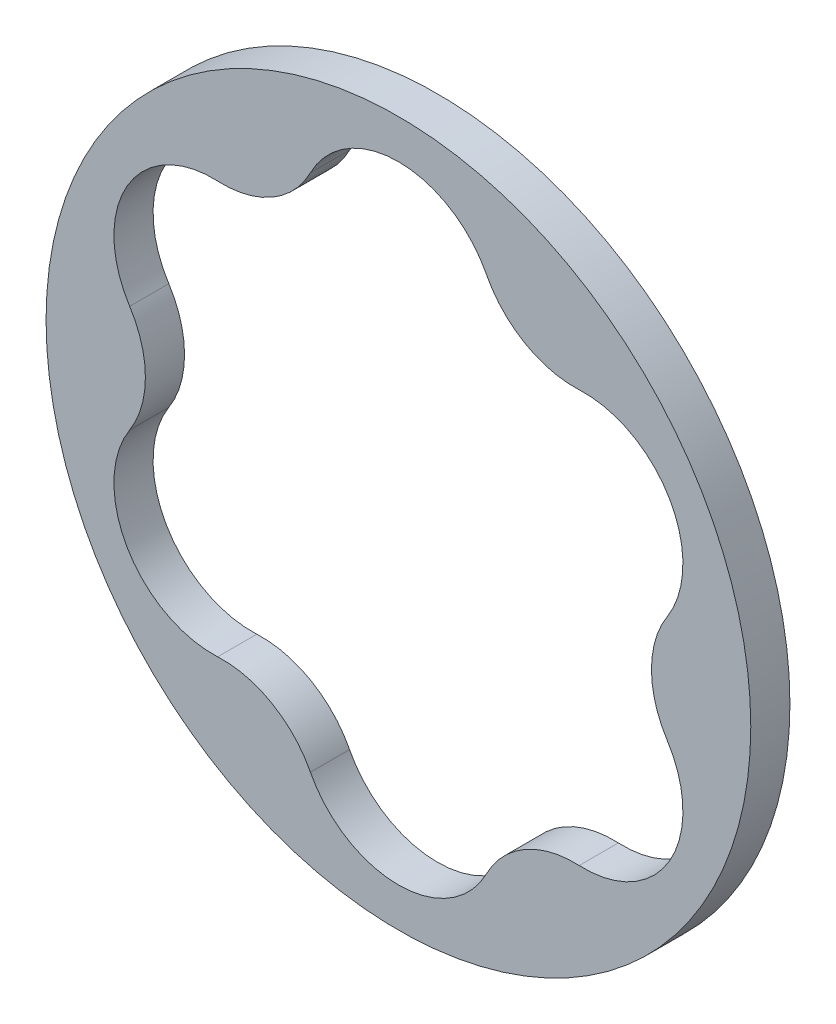
from build123d import *

# Parameters (mm, degrees)
SKETCH1_R           = 14.2875
BOSS_EXTRUDE1_DEPTH = 0.79375
CUT_EXTRUDE1_DEPTH  = 2.5875


with BuildPart() as part:
    # Sketch1 → Boss-Extrude1 (new body, symmetric)
    with BuildSketch(Plane.XY):
        Circle(SKETCH1_R)
    extrude(amount=BOSS_EXTRUDE1_DEPTH, both=True)

    # Sketch2 → Cut-Extrude1 (cut, through all)
    with BuildSketch(Plane(origin=(0, 0, -0.79375), x_dir=(-1, 0, 0), z_dir=(0, 0, -1))):
        with BuildLine():
            ThreePointArc((-7.329682086, 8.352449747), (-5.130117272, 8.885623765), (-3.568592622, 10.523915761))
            ThreePointArc((-3.568592622, 10.523915761), (0, 12.7), (3.568592622, 10.523915761))
            ThreePointArc((3.568592622, 10.523915761), (5.130117272, 8.885623765), (7.329682086, 8.352449747))
            ThreePointArc((7.329682086, 8.352449747), (10.998522628, 6.35), (10.898274707, 2.171466014))
            ThreePointArc((10.898274707, 2.171466014), (10.260234545, 0), (10.898274707, -2.171466014))
            ThreePointArc((10.898274707, -2.171466014), (10.998522628, -6.35), (7.329682086, -8.352449747))
            ThreePointArc((7.329682086, -8.352449747), (5.130117272, -8.885623765), (3.568592622, -10.523915761))
            ThreePointArc((3.568592622, -10.523915761), (0, -12.7), (-3.568592622, -10.523915761))
            ThreePointArc((-3.568592622, -10.523915761), (-5.130117272, -8.885623765), (-7.329682086, -8.352449747))
            ThreePointArc((-7.329682086, -8.352449747), (-10.998522628, -6.35), (-10.898274707, -2.171466014))
            ThreePointArc((-10.898274707, -2.171466014), (-10.260234545, 0), (-10.898274707, 2.171466014))
            ThreePointArc((-10.898274707, 2.171466014), (-10.998522628, 6.35), (-7.329682086, 8.352449747))
        make_face()
    extrude(amount=-CUT_EXTRUDE1_DEPTH, mode=Mode.SUBTRACT)


solid = part.part
